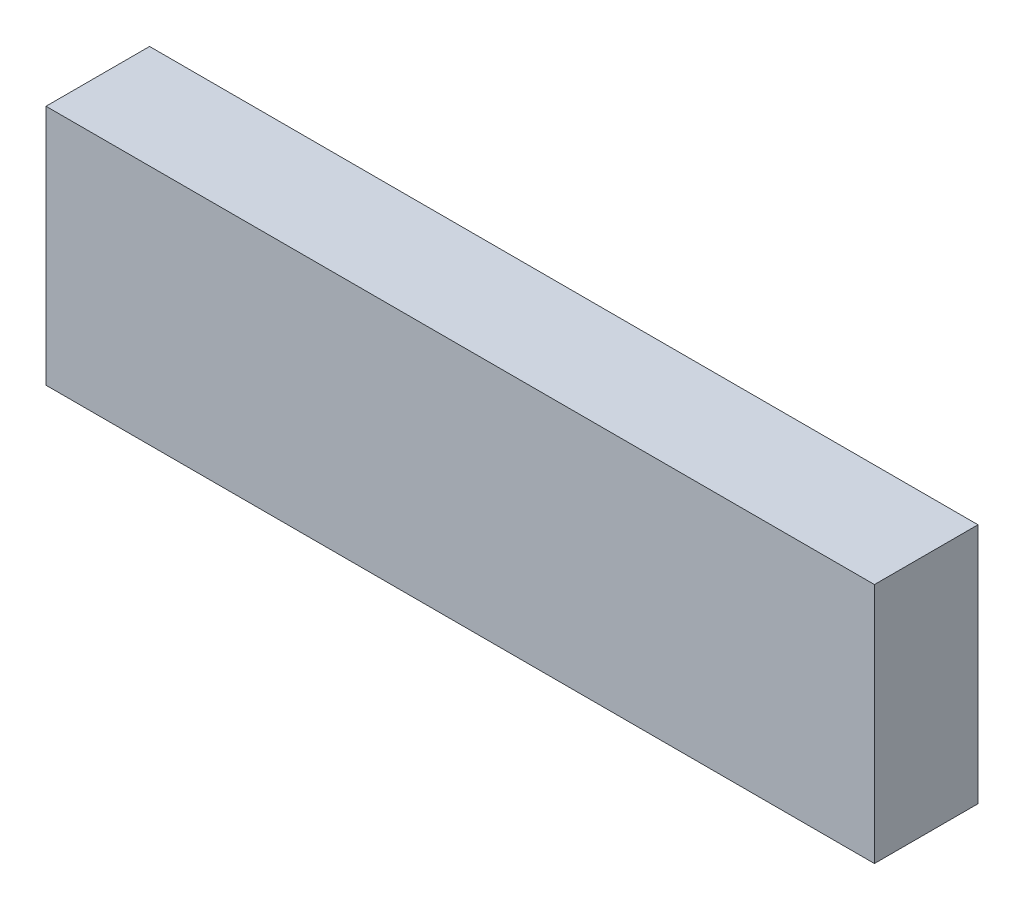
from build123d import *

# Parameters (mm, degrees)
SKETCH1_W           = 38.1
SKETCH1_H           = 88.9
BOSS_EXTRUDE1_DEPTH = 304.8


with BuildPart() as part:
    # Sketch1 → Boss-Extrude1 (new body)
    with BuildSketch(Plane(origin=(0, 0, 0), x_dir=(0, 0, -1), z_dir=(1, 0, 0))):
        Rectangle(SKETCH1_W, SKETCH1_H)
    extrude(amount=BOSS_EXTRUDE1_DEPTH)


solid = part.part
